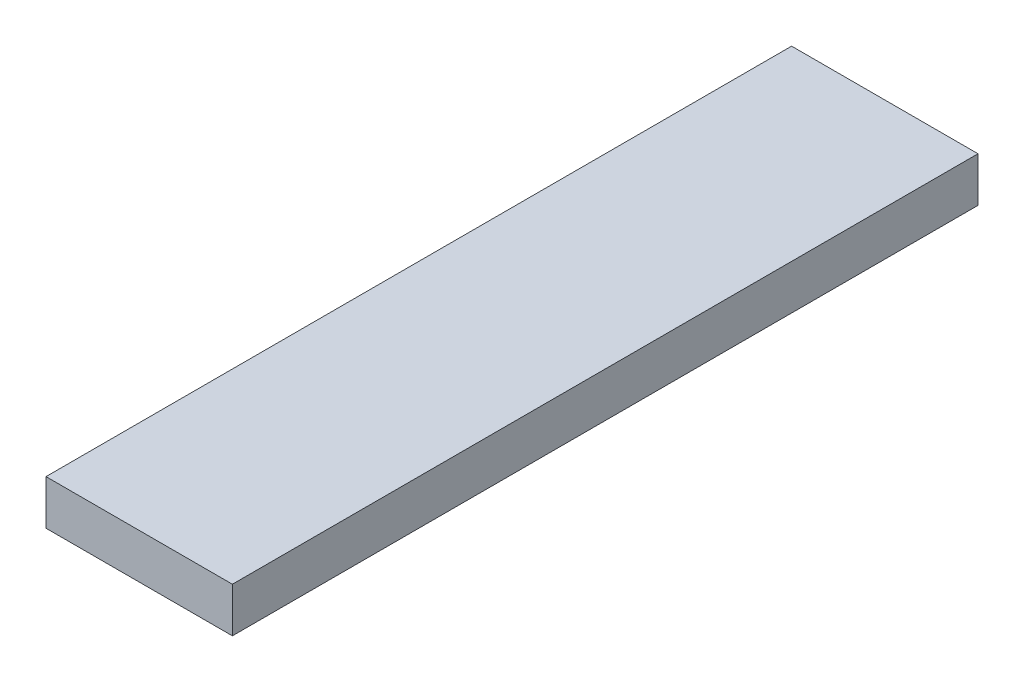
from build123d import *

# Parameters (mm, degrees)
SKETCH1_W           = 40
SKETCH1_H           = 2.4
BOSS_EXTRUDE1_DEPTH = 10


with BuildPart() as part:
    # Sketch1 → Boss-Extrude1 (new body)
    with BuildSketch(Plane(origin=(0, 0, 0), x_dir=(0, 0, -1), z_dir=(1, 0, 0))):
        with Locations((20, 1.2)):
            Rectangle(SKETCH1_W, SKETCH1_H)
    extrude(amount=BOSS_EXTRUDE1_DEPTH)


solid = part.part
